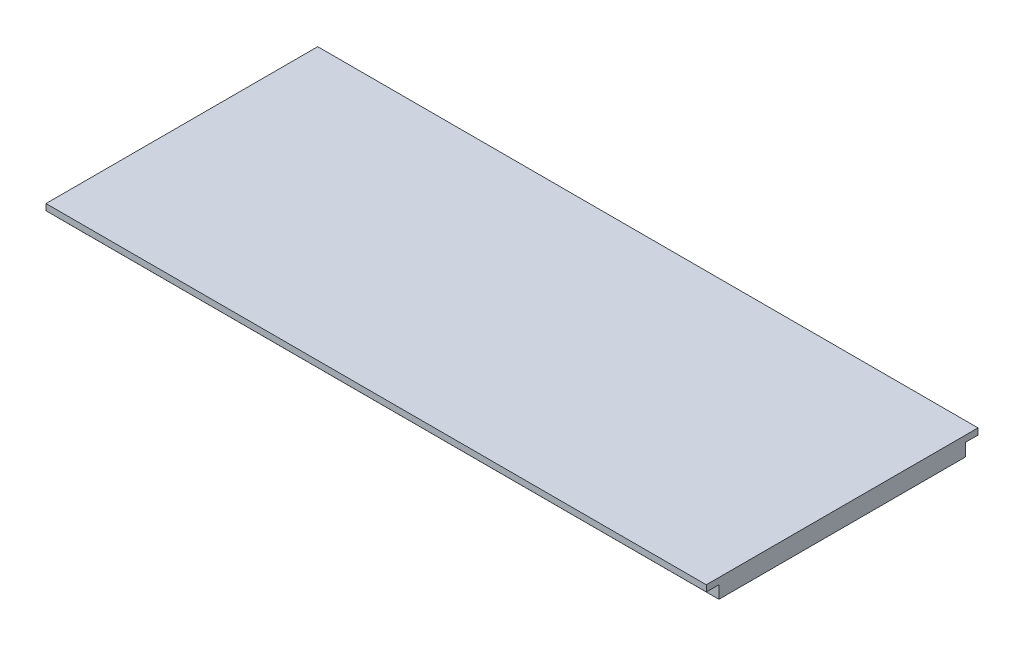
from build123d import *

# Parameters (mm, degrees)
BOSS_EXTRUDE1_DEPTH = 104.492
BOSS_EXTRUDE2_START = -63.5
BOSS_EXTRUDE2_DEPTH = 38.1
CUT_EXTRUDE1_REACH  = 173.872
SKETCH3_W           = 22.86
SKETCH3_H           = 11.793256687


with BuildPart() as part:
    # Sketch1 → Boss-Extrude1 (new body)
    with BuildSketch(Plane.ZY.offset(151.558859737)):
        Polygon((39.585382545, -1.394916167), (59.085382545, -1.394916167), (59.085382545, 1.605083833), (37.585382545, 1.605083833), (37.585382545, 0.613083833), (39.585382545, 0.613083833), align=None)
        Polygon((59.085382545, 1.605083833), (59.085382545, -1.394916167), (78.585382545, -1.394916167), (78.585382545, 0.613083833), (80.585382545, 0.613083833), (80.585382545, 1.605083833), align=None)
    extrude(amount=-BOSS_EXTRUDE1_DEPTH)

    # Sketch2 → Boss-Extrude2 (add)
    with BuildSketch(Plane.ZY.offset(151.558859737).offset(BOSS_EXTRUDE2_START)):
        with BuildLine():
            Line((62.967687953, -1.394916167), (59.566797506, -1.394916167))
            add(Edge.make_bspline(
                [(59.566797506, -1.394916167), (61.516069344, -1.480296614), (64.614879002, -4.048941964), (61.888012097, -9.907513109), (51.256243325, -7.093087206), (44.064836064, -1.702421731), (37.384560103, -4.548609474)],
                knots=[0, 0, 0, 0, 0.142255207, 0.248971974, 0.49110112, 1, 1, 1, 1], degree=3))
            ThreePointArc((37.384560103, -4.548609474), (37.00946558, -5.398654021), (37.882355942, -5.716984115))
            add(Edge.make_bspline(
                [(62.967687953, -1.394916167), (63.267997692, -1.632578173), (63.916012108, -2.255332587), (64.675351176, -3.439321761), (65.011296331, -5.012764351), (64.761227306, -6.477231249), (64.15882492, -7.745636277), (63.294119047, -8.794777149), (62.226334271, -9.548212989), (60.659956966, -10.115948294), (58.640135057, -10.149158727), (56.26343683, -9.58927774), (53.214845261, -8.448093107), (49.756760087, -6.806606324), (46.522726499, -5.454919618), (43.981015061, -4.862061183), (42.062111219, -4.719397121), (40.393533949, -4.908971794), (38.998126573, -5.281106442), (38.242951495, -5.563349347), (37.882355942, -5.716984115)],
                knots=[0.07063518, 0.07063518, 0.07063518, 0.07063518, 0.09375, 0.125, 0.15625, 0.1875, 0.21875, 0.25, 0.28125, 0.3125, 0.375, 0.4375, 0.5, 0.625, 0.75, 0.8125, 0.875, 0.9375, 0.96875, 1, 1, 1, 1], degree=3))
        make_face()
    extrude(amount=BOSS_EXTRUDE2_DEPTH)

    # Sketch3 → Cut-Extrude1 (cut, up to next)
    with BuildSketch(Plane(origin=(0, -1.394916167, 0), x_dir=(-1, 0, 0), z_dir=(0, -1, 0)), mode=Mode.PRIVATE) as cut_extrude1_sk1:
        with Locations((107.108859737, -51.398984286)):
            Rectangle(SKETCH3_W, SKETCH3_H)
    cut_extrude1_tool1 = extrude(cut_extrude1_sk1.sketch, amount=CUT_EXTRUDE1_REACH, mode=Mode.PRIVATE) & part.part
    add(cut_extrude1_tool1.solids().sort_by_distance((-107.10886, -1.394916, 51.398984))[0], mode=Mode.SUBTRACT)


solid = part.part
